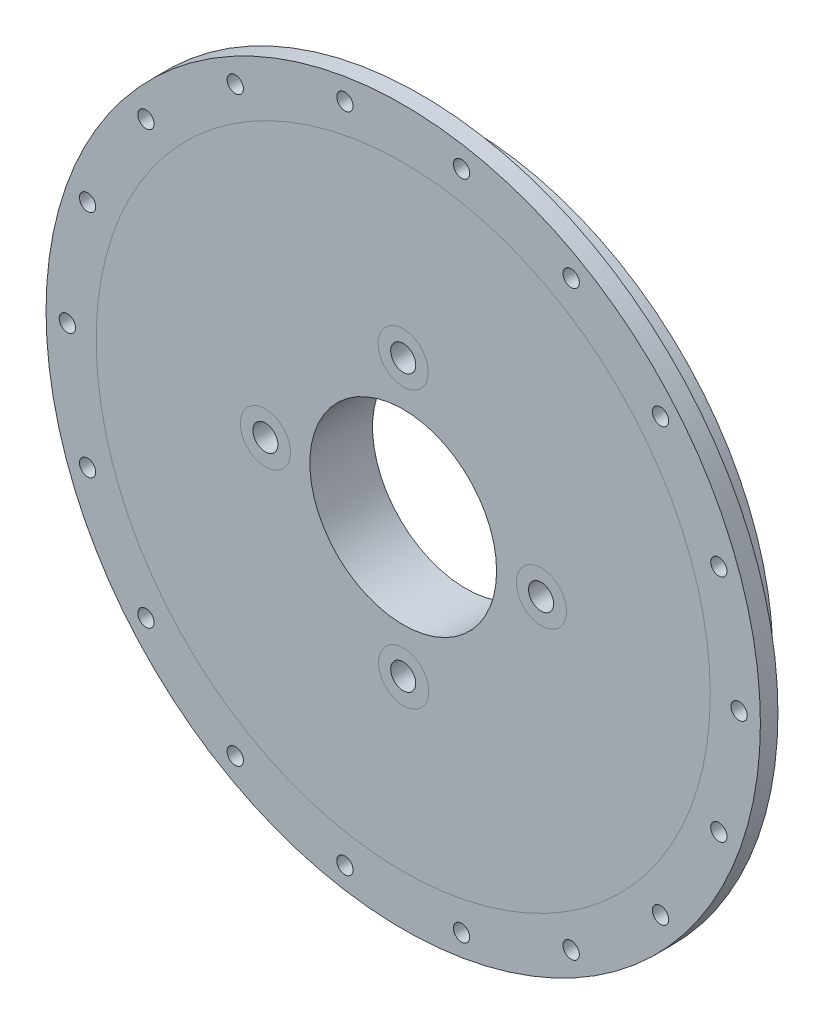
from build123d import *

# Parameters (mm, degrees)
SKETCH1_R           = 142.5
SKETCH1_R_2         = 3.25
SKETCH1_R_3         = 37.25
SKETCH1_R_4         = 5
BOSS_EXTRUDE1_DEPTH = 25
SKETCH5_R           = 142.5
SKETCH5_R_2         = 122.5
CUT_EXTRUDE2_DEPTH  = 18


with BuildPart() as part:
    # Sketch1 → Boss-Extrude1 (new body)
    with BuildSketch(Plane.XY):
        Circle(SKETCH1_R)
        with Locations((-23.268855807, 131.964238904)):
            Circle(SKETCH1_R_2, mode=Mode.SUBTRACT)
        with Locations((23.268855807, 131.964238904)):
            Circle(SKETCH1_R_2, mode=Mode.SUBTRACT)
        with Locations((67, 116.047404107)):
            Circle(SKETCH1_R_2, mode=Mode.SUBTRACT)
        with Locations((102.649955378, 86.133539698)):
            Circle(SKETCH1_R_2, mode=Mode.SUBTRACT)
        with Locations((125.918811185, 45.830699206)):
            Circle(SKETCH1_R_2, mode=Mode.SUBTRACT)
        with Locations((134, 0)):
            Circle(SKETCH1_R_2, mode=Mode.SUBTRACT)
        with Locations((125.918811185, -45.830699206)):
            Circle(SKETCH1_R_2, mode=Mode.SUBTRACT)
        with Locations((102.649955378, -86.133539698)):
            Circle(SKETCH1_R_2, mode=Mode.SUBTRACT)
        with Locations((67, -116.047404107)):
            Circle(SKETCH1_R_2, mode=Mode.SUBTRACT)
        with Locations((23.268855807, -131.964238904)):
            Circle(SKETCH1_R_2, mode=Mode.SUBTRACT)
        with Locations((-23.268855807, -131.964238904)):
            Circle(SKETCH1_R_2, mode=Mode.SUBTRACT)
        with Locations((-67, -116.047404107)):
            Circle(SKETCH1_R_2, mode=Mode.SUBTRACT)
        with Locations((-102.649955378, -86.133539698)):
            Circle(SKETCH1_R_2, mode=Mode.SUBTRACT)
        with Locations((-125.918811185, -45.830699206)):
            Circle(SKETCH1_R_2, mode=Mode.SUBTRACT)
        with Locations((-134, 0)):
            Circle(SKETCH1_R_2, mode=Mode.SUBTRACT)
        with Locations((-125.918811185, 45.830699206)):
            Circle(SKETCH1_R_2, mode=Mode.SUBTRACT)
        with Locations((-102.649955378, 86.133539698)):
            Circle(SKETCH1_R_2, mode=Mode.SUBTRACT)
        with Locations((-67, 116.047404107)):
            Circle(SKETCH1_R_2, mode=Mode.SUBTRACT)
        Circle(SKETCH1_R_3, mode=Mode.SUBTRACT)
        with Locations((0, 55)):
            Circle(SKETCH1_R_4, mode=Mode.SUBTRACT)
        with Locations((55, 0)):
            Circle(SKETCH1_R_4, mode=Mode.SUBTRACT)
        with Locations((0, -55)):
            Circle(SKETCH1_R_4, mode=Mode.SUBTRACT)
        with Locations((-55, 0)):
            Circle(SKETCH1_R_4, mode=Mode.SUBTRACT)
    extrude(amount=BOSS_EXTRUDE1_DEPTH)

    # Sketch5 → Cut-Extrude2 (cut)
    with BuildSketch(Plane(origin=(0, 0, 0), x_dir=(-1, 0, 0), z_dir=(0, 0, -1))):
        Circle(SKETCH5_R)
        Circle(SKETCH5_R_2, mode=Mode.SUBTRACT)
    extrude(amount=-CUT_EXTRUDE2_DEPTH, mode=Mode.SUBTRACT)


solid = part.part
